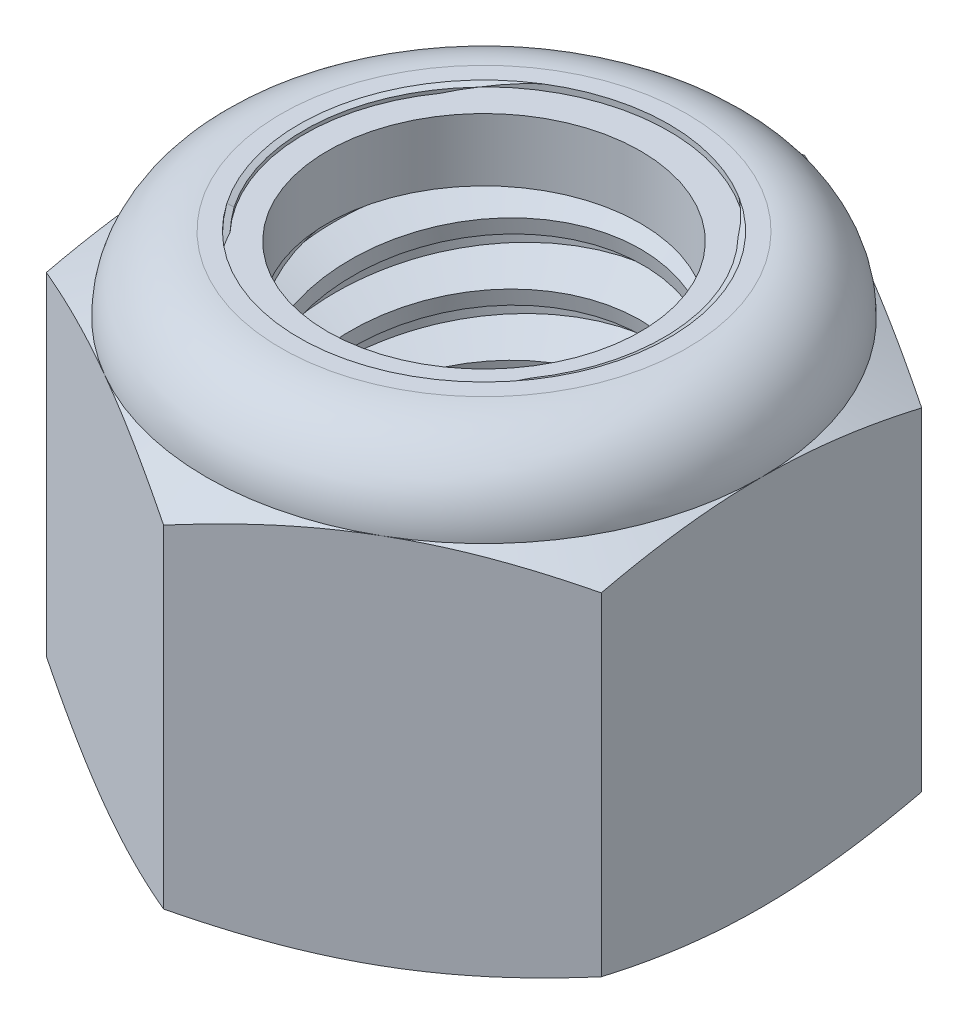
from build123d import *

# Parameters (mm, degrees)
EXTRUDE1_DEPTH      = 11.509375
SKETCH2_W           = 4.7625
SKETCH2_H           = 11.509375
LPATTERN1_COUNT     = 7
LPATTERN1_PITCH     = 1.5875
LPATTERN1_COL_COUNT = 2
LPATTERN1_COL_PITCH = 1.5875


with BuildPart() as part:
    # Sketch1 → Extrude1 (new body)
    with BuildSketch(Plane(origin=(0, 0, 0), x_dir=(1, 0, 0), z_dir=(0, 1, 0))):
        Polygon((0, 8.248891971), (-7.14375, 4.124445986), (-7.14375, -4.124445986), (0, -8.248891971), (7.14375, -4.124445986), (7.14375, 4.124445986), align=None)
    extrude(amount=EXTRUDE1_DEPTH)

    # Sketch4 → Cut-Revolve2 (revolve, cut)
    with BuildSketch(Plane(origin=(0, 0, 0), x_dir=(0, 0, -1), z_dir=(1, 0, 0))):
        Polygon((0, 11.509375), (4.7625, 11.509375), (4.029111805, 11.167390468), (4.029111805, 0.341984532), (4.7625, 0), (0, 0), align=None)
    revolve(axis=Axis((0, 11.509375, 0), (0, 1, 0)), mode=Mode.SUBTRACT)


with BuildPart() as body_2:
    # Sketch2 → Revolve1 (revolve)
    with BuildSketch(Plane(origin=(0, 0, 0), x_dir=(0, 0, -1), z_dir=(1, 0, 0))):
        with Locations((2.38125, 5.7546875)):
            Rectangle(SKETCH2_W, SKETCH2_H)
    revolve(axis=Axis((0, -4.7625, 0), (0, 1, 0)))

    # Sketch3 → Cut-Revolve1 (revolve, cut)
    with BuildSketch(Plane(origin=(0, 0, 0), x_dir=(0, 0, -1), z_dir=(1, 0, 0))):
        Polygon((4.795122924, 11.313637456), (5.023483392, 9.943474646), (4.094357653, 10.291557102), (4.029111805, 10.68303219), align=None)
    cut_revolve1 = revolve(axis=Axis((0, 11.509375, 0.28317269), (0, -0.986393924, -0.164398987)), mode=Mode.SUBTRACT)

    # LPattern1: Cut-Revolve1 ×7
    with Locations(*[(0, -i * LPATTERN1_PITCH, 0) for i in range(1, LPATTERN1_COUNT)]):
        add(cut_revolve1, mode=Mode.SUBTRACT)

    # LPattern1 col: Cut-Revolve1 ×2
    with Locations(*[(0, i * LPATTERN1_COL_PITCH, 0) for i in range(1, LPATTERN1_COL_COUNT)]):
        add(cut_revolve1, mode=Mode.SUBTRACT)


with BuildPart() as part_1:
    add(part.part)

    # Combine1: cut body 2
    add(body_2.part, mode=Mode.SUBTRACT)

    # Sketch5 → Cut-Revolve3 (revolve, cut)
    with BuildSketch(Plane(origin=(0, 0, 0), x_dir=(0, 0, -1), z_dir=(1, 0, 0))):
        with BuildLine():
            Line((0, 0), (7.14375, 0))
            Line((7.14375, 0), (8.248891971, 0.515336164))
            Line((8.248891971, 0.515336164), (8.248891971, 9.075809669))
            Line((8.248891971, 9.075809669), (7.14375, 9.591145833))
            ThreePointArc((7.14375, 9.591145833), (6.581913685, 10.947538685), (5.225520833, 11.509375))
            Line((5.225520833, 11.509375), (5.225520833, 12.779375))
            Line((5.225520833, 12.779375), (9.518891971, 12.779375))
            Line((9.518891971, 12.779375), (9.518891971, -1.27))
            Line((9.518891971, -1.27), (0, -1.27))
            Line((0, -1.27), (0, 0))
        make_face()
    revolve(axis=Axis((0, 0, 0), (0, 1, 0)), mode=Mode.SUBTRACT)

    # Sketch6 → Cut-Revolve4 (revolve, cut)
    with BuildSketch(Plane(origin=(0, 0, 0), x_dir=(0, 0, -1), z_dir=(1, 0, 0))):
        with BuildLine():
            Line((0, 9.591145833), (6.99135, 9.591145833))
            ThreePointArc((6.99135, 9.591145833), (6.474150612, 10.839775612), (5.225520833, 11.356975))
            Line((5.225520833, 11.356975), (4.627316319, 11.356975))
            Line((4.627316319, 11.356975), (4.627316319, 12.779375))
            Line((4.627316319, 12.779375), (0, 12.779375))
            Line((0, 12.779375), (0, 9.591145833))
        make_face()
    revolve(axis=Axis((0, 12.779375, 0), (0, 1, 0)), mode=Mode.SUBTRACT)


with BuildPart() as body_2_2:
    # Sketch7 → Revolve2 (revolve)
    with BuildSketch(Plane(origin=(0, 0, 0), x_dir=(0, 0, -1), z_dir=(1, 0, 0))):
        with BuildLine():
            Line((4.029111805, 9.667345833), (6.913430867, 9.667345833))
            ThreePointArc((6.913430867, 9.667345833), (6.39301751, 10.812537757), (5.225520833, 11.280775))
            Line((5.225520833, 11.280775), (4.029111805, 11.280775))
            Line((4.029111805, 11.280775), (4.029111805, 9.667345833))
        make_face()
    revolve(axis=Axis((0, 9.667345833, 0), (0, 1, 0)))


solid = Compound([part_1.part, body_2_2.part])
